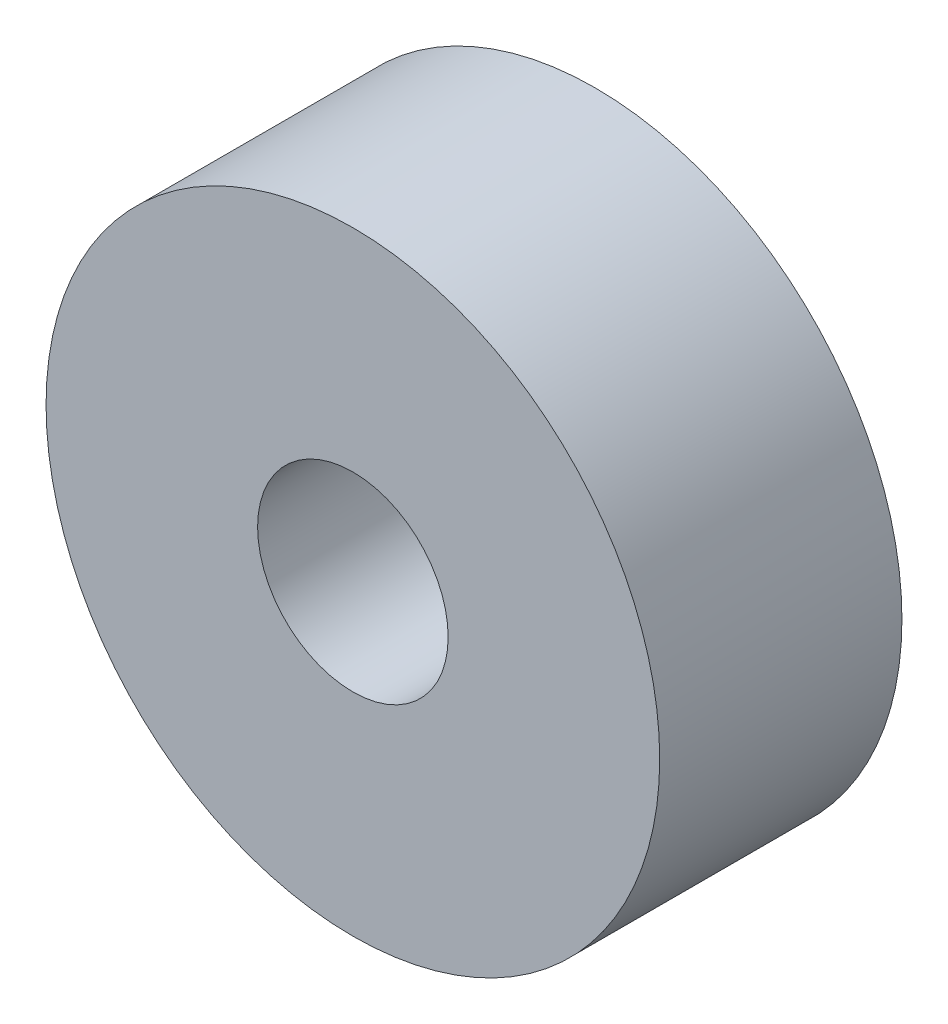
from build123d import *

# Parameters (mm, degrees)
SKETCH1_R          = 9.5
MAIN_EXTRUDE_DEPTH = 7.5
SKETCH2_R          = 2.95
CUT_EXTRUDE1_DEPTH = 10


with BuildPart() as part:
    # Sketch1 → Main Extrude (new body)
    with BuildSketch(Plane.XY):
        Circle(SKETCH1_R)
    extrude(amount=MAIN_EXTRUDE_DEPTH)

    # Sketch2 → Cut-Extrude1 (cut)
    with BuildSketch(Plane.XY.offset(7.5)):
        Circle(SKETCH2_R)
    extrude(amount=-CUT_EXTRUDE1_DEPTH, mode=Mode.SUBTRACT)


solid = part.part
